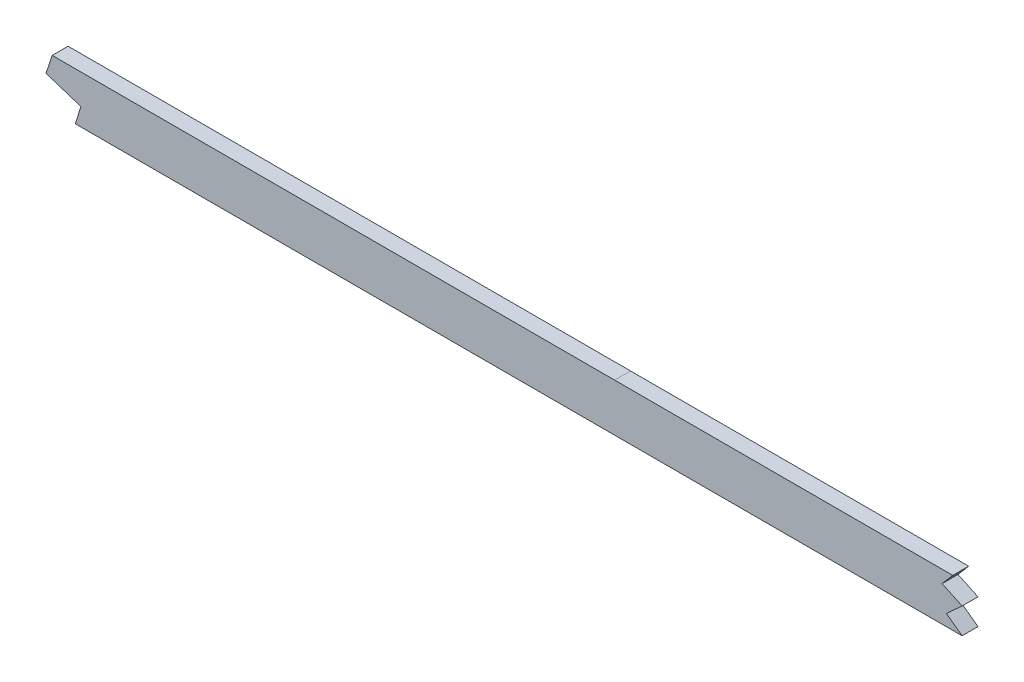
from build123d import *

# Parameters (mm, degrees)
BOSS_EXTRUDE1_DEPTH = 3.175
CUT_EXTRUDE1_DEPTH  = 7.3500001
FILLET1_R           = 2.54
CUT_EXTRUDE2_DEPTH  = 7.62


with BuildPart() as part:
    # Sketch1 → Boss-Extrude1 (new body, symmetric)
    with BuildSketch(Plane.XY):
        with BuildLine():
            Line((499.61002795, -53.470702797), (1046.28548189, -53.470702797))
            add(Edge.make_bspline(
                [(2669.54, -9.569049356), (2615.393603553, -13.17073937), (2561.080658619, -16.536108081), (2506.205230446, -19.758621957), (2430.209106802, -23.505211705), (2354.212983157, -26.631486423), (2332.570330468, -27.480988169), (2156.268639429, -34.377768543), (1979.966947376, -41.628631248), (1824.114277635, -52.771265877), (1636.928606778, -53.579569849), (1449.742935921, -53.454024613), (1418.006730935, -53.470702797), (1324.899336146, -53.470702797), (1231.791940344, -53.470702797), (1170.441269319, -53.470702797), (1108.784075813, -53.470702797), (1047.126882346, -53.470702797), (1046.846414188, -53.470702797), (1046.565947184, -53.470702797), (1046.28548189, -53.470702797)],
                knots=[103.698913506, 103.698913506, 103.698913506, 103.698913506, 103.698913506, 103.698913506, 130.927896619, 130.927896619, 130.927896619, 141.337054719, 141.337054719, 141.337054719, 218.101815019, 218.101815019, 218.101815019, 233.772059419, 233.772059419, 233.772059419, 264.077723219, 264.077723219, 264.077723219, 264.2162088, 264.2162088, 264.2162088, 264.2162088, 264.2162088, 264.2162088], degree=5))
            Line((2669.54, -9.569049356), (2669.54, 9.5231025))
            add(Edge.make_bspline(
                [(2669.54, 9.5231025), (2667.126494524, 9.36235515), (2659.861586685, 8.880281494), (2635.666282302, 7.292469146), (2596.857665529, 4.826056853), (2545.729743039, 1.758344093), (2494.405305707, -1.098555235), (2451.533022267, -3.266573297), (2417.198316756, -4.86708361), (2391.457076919, -6.003589235), (2365.634736307, -7.086854581), (2339.546284672, -8.137729944), (2313.466132974, -9.165138371), (2287.612375486, -10.179478215), (2261.763347437, -11.201032297), (2227.285329715, -12.583842557), (2184.175569393, -14.36607236), (2132.429066114, -16.607427868), (2063.4255234, -19.708920485), (1977.174907635, -23.700543313), (1873.732451432, -28.149389221), (1770.37461881, -31.657468649), (1667.085687813, -33.793117556), (1581.011094491, -34.383188831), (1512.07397126, -34.4278026), (1443.061513477, -34.409510402), (1356.800927879, -34.424432812), (1218.794626954, -34.418464788), (1115.289022786, -34.420702797), (1046.28548189, -34.420702797)],
                knots=[103.571582669, 103.571582669, 103.571582669, 103.571582669, 104.300777207, 105.766098403, 110.877392287, 115.98868617, 121.099980054, 126.211273938, 128.76692088, 131.322567822, 133.878214764, 136.433861706, 138.989508647, 141.545155589, 144.100802531, 146.656449473, 151.767743357, 156.879037241, 161.990331124, 172.212918892, 182.43550666, 192.658094427, 202.880682195, 213.103269962, 218.214563846, 223.32585773, 233.548445497, 243.771033265, 264.2162088, 264.2162088, 264.2162088, 264.2162088], degree=3))
            Line((1046.28548189, -34.420702797), (499.61002795, -34.420702797))
            add(Edge.make_bspline(
                [(499.61002795, -34.420702797), (488.614737518, -34.420702797), (472.236395365, -34.420702798), (449.940231846, -34.420702794), (427.771305695, -34.42070281), (405.874681663, -34.420702712), (384.584909128, -34.420702942), (368.900229326, -34.420702244), (353.376568613, -34.420704862), (332.608466435, -34.420689186), (306.287754853, -34.420570006), (274.023487704, -34.420538256), (252.271015965, -34.420709741), (241.425150134, -34.420702761)],
                knots=[19.90682951, 19.90682951, 19.90682951, 19.90682951, 23.220120017, 24.876765271, 26.533410525, 29.846701033, 31.503346286, 33.15999154, 34.816636794, 36.473282048, 39.786572556, 43.099863063, 46.413153571, 46.413153571, 46.413153571, 46.413153571], degree=3))
            add(Edge.make_bspline(
                [(241.425150134, -34.420702761), (239.394928853, -34.420701455), (235.322322927, -34.420495867), (227.274423443, -34.398702533), (217.319360062, -34.297466855), (205.530690077, -33.976385563), (189.963341914, -33.212641271), (170.696984653, -31.543495194), (147.533261232, -28.314398128), (125.482753206, -24.202109872), (109.358914834, -20.622537553), (100.964116069, -18.612521054), (99.06, -18.149327722)],
                knots=[0, 0, 0, 0, 0.622088422, 1.244176844, 2.488353689, 3.732530533, 4.976707377, 7.465061066, 9.953414755, 12.441768444, 14.55823542, 15.180323842, 15.180323842, 15.180323842, 15.180323842], degree=3))
            Line((99.06, -18.149327722), (99.06, -37.741485304))
            add(Edge.make_bspline(
                [(241.425137875, -53.470702761), (224.286916993, -53.470691732), (207.149474967, -53.467315374), (190.203897513, -52.686577078), (161.734965878, -49.987457476), (133.266034188, -45.175583375), (121.749620566, -42.910592695), (110.349390726, -40.420274627), (99.06, -37.741485304)],
                knots=[0, 0, 0, 0, 0, 0, 8.71381608, 8.71381608, 8.71381608, 14.701907176, 14.701907176, 14.701907176, 14.701907176, 14.701907176, 14.701907176], degree=5))
            add(Edge.make_bspline(
                [(499.61002795, -53.470702797), (492.136820835, -53.470702797), (484.754348064, -53.470702797), (477.443025859, -53.470702797), (448.516583145, -53.470702797), (419.590140517, -53.470702797), (398.368118521, -53.470702797), (355.647540186, -53.470702797), (312.926961851, -53.470702797), (289.235090436, -53.470293029), (265.364963651, -53.470705034), (241.4948369, -53.470702789), (241.471603891, -53.470702785), (241.448370882, -53.470702776), (241.425137875, -53.470702761)],
                knots=[19.90682951, 19.90682951, 19.90682951, 19.90682951, 19.90682951, 19.90682951, 23.637897311, 23.637897311, 23.637897311, 34.276545571, 34.276545571, 34.276545571, 46.401340901, 46.401340901, 46.401340901, 46.413153571, 46.413153571, 46.413153571, 46.413153571, 46.413153571, 46.413153571], degree=5))
        make_face()
    extrude(amount=BOSS_EXTRUDE1_DEPTH, both=True)

    # Sketch2 → Cut-Extrude1 (cut, through all)
    with BuildSketch(Plane.XY.offset(3.175)):
        with BuildLine():
            add(Edge.make_bspline(
                [(2312.9875, -9.183260037), (2304.505441691, -9.516700376), (2287.441020622, -10.186250162), (2261.763347437, -11.201032297), (2228.230552004, -12.545932515), (2203.310445107, -13.575047161), (2187.00995947, -14.263260037)],
                knots=[139.04033329, 139.04033329, 139.04033329, 139.04033329, 141.545155589, 144.100802531, 146.656449473, 151.487488909, 151.487488909, 151.487488909, 151.487488909], degree=3))
            Line((2187.00995947, -14.263260037), (2312.9875, -14.263260037))
            Line((2312.9875, -14.263260037), (2312.9875, -9.183260037))
        make_face()
    extrude(amount=-CUT_EXTRUDE1_DEPTH, mode=Mode.SUBTRACT)

    # Fillet1
    fillet1_edges = [part.edges().sort_by_distance(p)[0] for p in [
        (2669.54, -9.569049356, -1.5875),
        (2669.54, 9.5231025, -1.5875),
        (99.06, -37.741485304, -1.5875),
        (99.06, -18.149327722, -1.5875),
        (2312.9875, -9.183260037, 1.5875),
        (2312.9875, -14.263260037, 0),
    ]]
    fillet(fillet1_edges, radius=FILLET1_R)

    # Sketch3 → Cut-Extrude2 (cut)
    with BuildSketch(Plane.XY.offset(3.175)):
        Polygon((821.518882755, -34.420702797), (819.047328197, -41.874419167), (833.004793216, -46.384200616), (830.756310042, -53.470702797), (833.004793216, -88.377214401), (71.333278148, -146.659078969), (65.822633249, 75.523734032), (821.518882755, 94.266739515), align=None)
        Polygon((1181.433983433, -34.420040525), (1177.136382458, -39.41105826), (1185.135968065, -43.161373269), (1178.857838528, -48.879066642), (1185.135968065, -53.470702797), (1178.857838528, -73.832795228), (2840.460279362, -301.9320282), (2840.460279362, 201.131978716), (1181.433983433, 94.266739515), align=None)
    extrude(amount=-CUT_EXTRUDE2_DEPTH, mode=Mode.SUBTRACT)


solid = part.part
